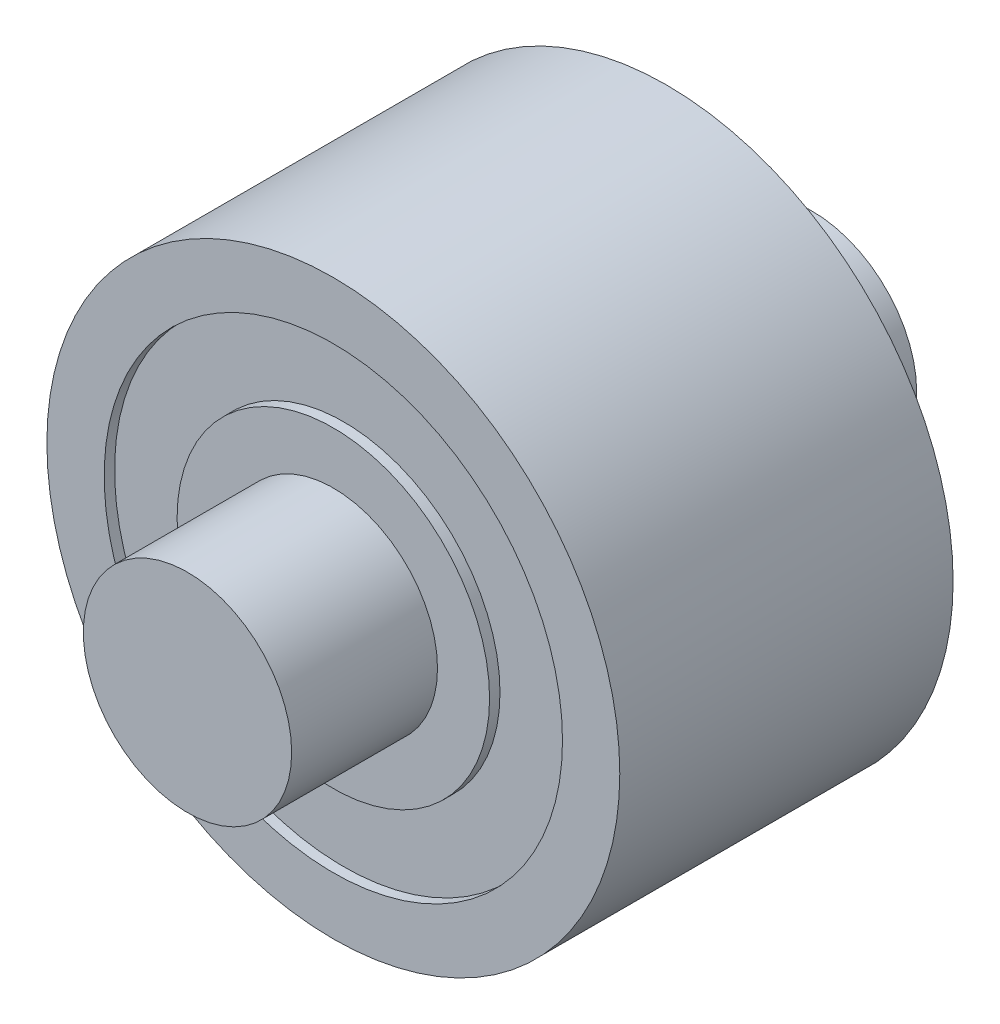
from build123d import *

# Parameters (mm, degrees)
CROQUIS1_R              = 11
SALIENTE_EXTRUIR1_DEPTH = 12.8
CROQUIS2_R              = 8.8
CROQUIS2_R_2            = 6
CORTAR_EXTRUIR1_DEPTH   = 0.4
CROQUIS3_R              = 4
SALIENTE_EXTRUIR2_DEPTH = 5.6


with BuildPart() as part:
    # Croquis1 → Saliente-Extruir1 (new body)
    with BuildSketch(Plane.XY):
        Circle(CROQUIS1_R)
    extrude(amount=SALIENTE_EXTRUIR1_DEPTH)

    # Croquis2 → Cortar-Extruir1 (cut)
    with BuildSketch(Plane.XY.offset(12.8)):
        Circle(CROQUIS2_R)
        Circle(CROQUIS2_R_2, mode=Mode.SUBTRACT)
    cortar_extruir1 = extrude(amount=-CORTAR_EXTRUIR1_DEPTH, mode=Mode.SUBTRACT)

    # Croquis3 → Saliente-Extruir2 (add)
    with BuildSketch(Plane.XY.offset(12.8)):
        Circle(CROQUIS3_R)
    saliente_extruir2 = extrude(amount=SALIENTE_EXTRUIR2_DEPTH)

    # Simetría1: Cortar-Extruir1, Saliente-Extruir2 across plane
    add(cortar_extruir1.mirror(Plane.XY.offset(6.4)), mode=Mode.SUBTRACT)
    add(saliente_extruir2.mirror(Plane.XY.offset(6.4)))


solid = part.part
